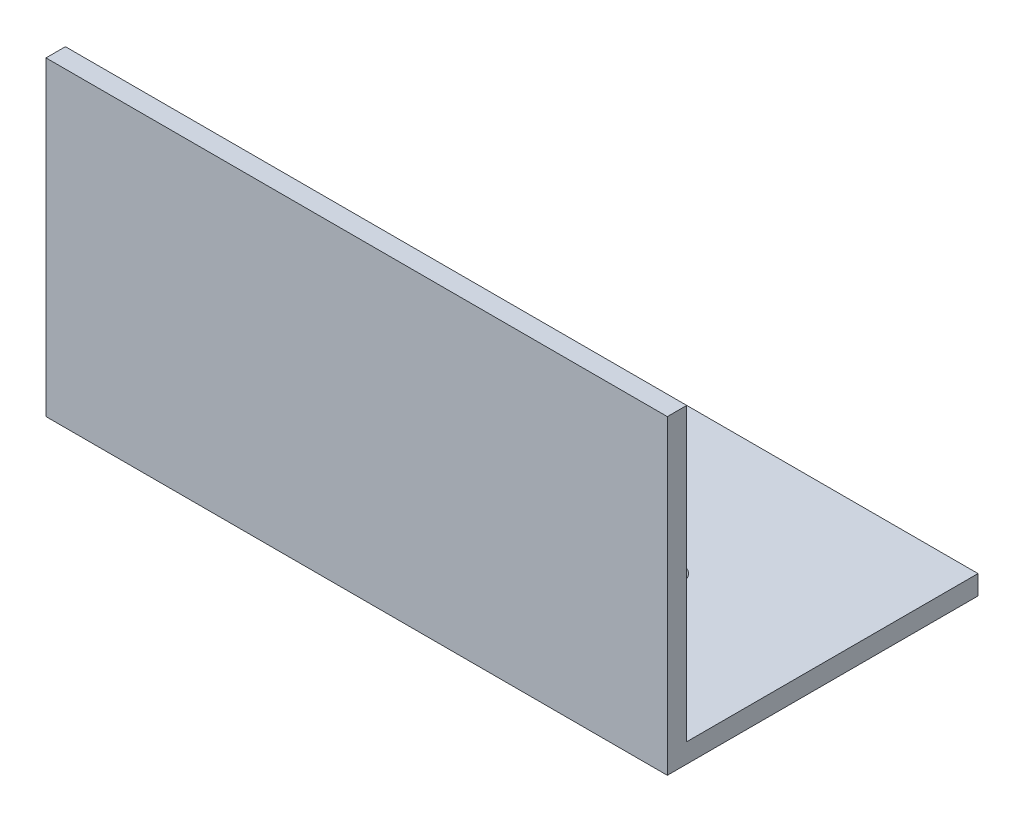
from build123d import *

# Parameters (mm, degrees)
BOSS_EXTRUDE1_DEPTH          = 101.6
F_10_0_1935_DIAMETER_HOLE1_D = 4.9149


with BuildPart() as part:
    # Sketch1 → Boss-Extrude1 (new body)
    with BuildSketch(Plane(origin=(0, 0, 0), x_dir=(0, 0, -1), z_dir=(1, 0, 0))):
        Polygon((0, 0), (0, 50.8), (3.175, 50.8), (3.175, 3.175), (50.8, 3.175), (50.8, 0), align=None)
    extrude(amount=BOSS_EXTRUDE1_DEPTH)

    # #10 (0.1935) Diameter Hole1 (through all)
    with Locations(Plane(origin=(0, 0, 0), x_dir=(-1, 0, 0), z_dir=(0, -1, 0))):
        with Locations((-76.2, 25.4), (-25.4, 25.4)):
            Hole(F_10_0_1935_DIAMETER_HOLE1_D / 2)


solid = part.part
